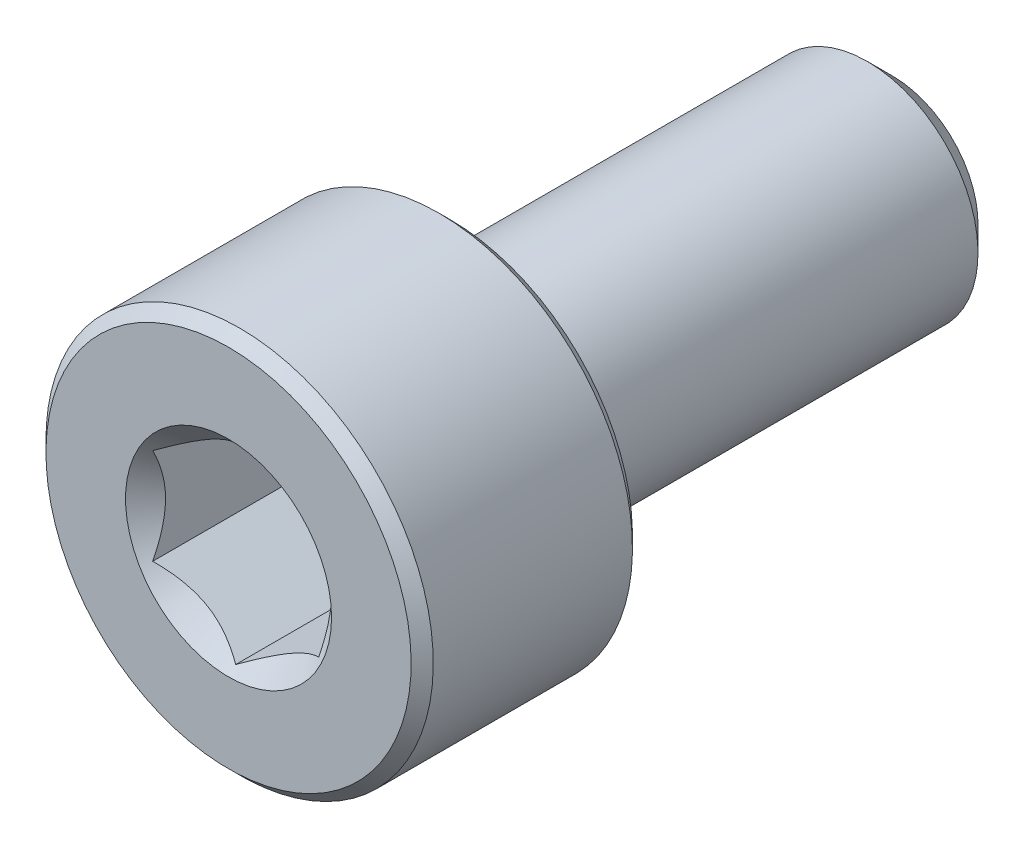
from build123d import *

# Parameters (mm, degrees)
CUT_EXTRUDE1_DEPTH = 3
SKETCH4_R          = 1.861954618
CUT_EXTRUDE2_DEPTH = 3
CUT_EXTRUDE2_DRAFT = -45


with BuildPart() as part:
    # Sketch2 → Revolve1 (revolve)
    with BuildSketch(Plane(origin=(0, 0, 0), x_dir=(0, 0, -1), z_dir=(1, 0, 0))):
        with BuildLine():
            Line((-6, 0), (-6, 3.3))
            Line((-6, 3.3), (-5.8, 3.5))
            Line((-5.8, 3.5), (-2.2, 3.5))
            Line((-2.2, 3.5), (-2, 3.3))
            Line((-2, 3.3), (-2, 2.2))
            ThreePointArc((-2, 2.2), (-1.941421356, 2.058578644), (-1.8, 2))
            Line((-1.8, 2), (5.545336663, 2))
            Line((5.545336663, 2), (6, 1.545336663))
            Line((6, 1.545336663), (6, 0))
            Line((6, 0), (-6, 0))
        make_face()
    revolve(axis=Axis((0, 0, -6), (0, 0, 1)))

    # Sketch3 → Cut-Extrude1 (cut)
    with BuildSketch(Plane.XY.offset(6)):
        Polygon((1.5, -0.866025404), (1.5, 0.866025404), (0, 1.732050808), (-1.5, 0.866025404), (-1.5, -0.866025404), (0, -1.732050808), align=None)
    extrude(amount=-CUT_EXTRUDE1_DEPTH, mode=Mode.SUBTRACT)


with BuildPart() as cut_extrude2_tool:
    # Sketch4 → Cut-Extrude2 (with draft: the straight prism first)
    with BuildSketch(Plane.XY.offset(6)):
        Circle(SKETCH4_R)
    extrude(amount=-CUT_EXTRUDE2_DEPTH)
    # Cut-Extrude2: the draft: its side faces are tilted about the plane it starts from
    cut_extrude2_sides = [cut_extrude2_tool.faces().sort_by_distance(p)[0] for p in [
        (-1.861954618, 0, 4.5),
    ]]
    draft(cut_extrude2_sides, Plane.XY.offset(6), CUT_EXTRUDE2_DRAFT)


with BuildPart() as part_1:
    add(part.part)

    # Cut-Extrude2: cut by cut_extrude2_tool
    add(cut_extrude2_tool.part, mode=Mode.SUBTRACT)


solid = part_1.part
